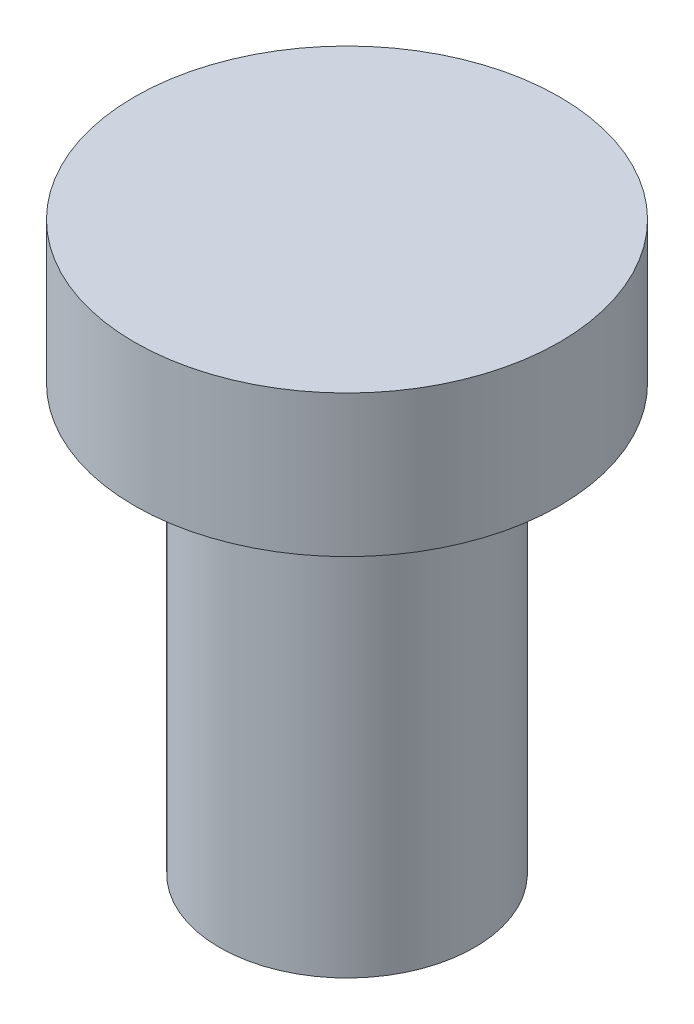
from build123d import *

# Parameters (mm, degrees)
SKETCH1_R           = 1.8
BOSS_EXTRUDE1_DEPTH = 6
SKETCH1_3_R         = 3
BOSS_EXTRUDE2_DEPTH = 2


with BuildPart() as part:
    # Sketch1 → Boss-Extrude1 (new body)
    with BuildSketch(Plane(origin=(0, 0, 0), x_dir=(1, 0, 0), z_dir=(0, 1, 0))):
        Circle(SKETCH1_R)
    extrude(amount=-BOSS_EXTRUDE1_DEPTH)

    # Sketch1_3 → Boss-Extrude2 (add)
    with BuildSketch(Plane(origin=(0, 0, 0), x_dir=(1, 0, 0), z_dir=(0, 1, 0))):
        Circle(SKETCH1_3_R)
    extrude(amount=BOSS_EXTRUDE2_DEPTH)


solid = part.part
